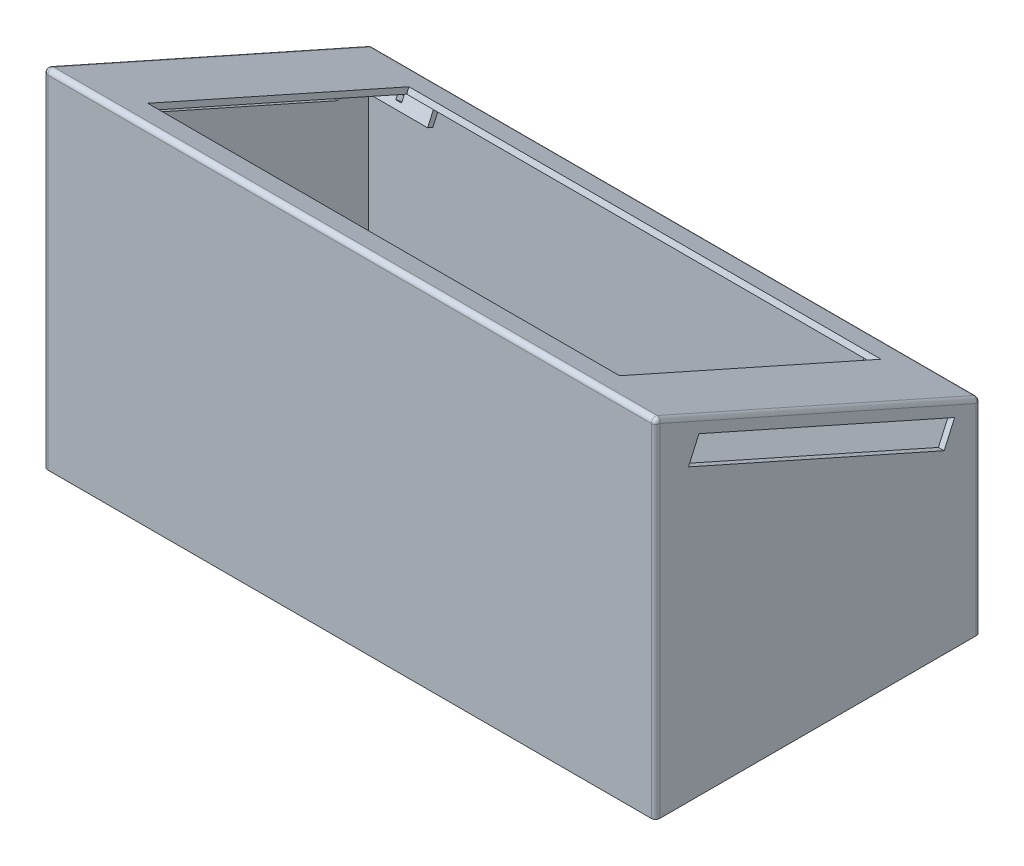
from build123d import *

# Parameters (mm, degrees)
EXTRUDE_1_DEPTH     = 210
SHELL_1_T           = 2
SKETCH_3_W          = 165
SKETCH_3_H          = 100
CUT_EXTRUDE_2_DEPTH = 2
EXTRUDE_2_DEPTH     = 6
CUT_EXTRUDE_3_DEPTH = 2
CUT_EXTRUDE_4_DEPTH = 2
CUT_EXTRUDE_5_DEPTH = 2
FILLET_1_R          = 1.5


with BuildPart() as part:
    # 草图2 → 凸台-拉伸1 (new body)
    with BuildSketch(Plane(origin=(0, 0, 0), x_dir=(0, 0, -1), z_dir=(1, 0, 0))):
        Polygon((0, 0), (0, 118.808397169), (109.625454917, 70), (109.625454917, 0), align=None)
    extrude(amount=EXTRUDE_1_DEPTH)

    # 抽壳1
    shell_1_openings = [part.faces().sort_by_distance(p)[0] for p in [
        (105, 0, -54.812727459),
    ]]
    offset(amount=SHELL_1_T, openings=shell_1_openings, kind=Kind.INTERSECTION)

    # 草图3 → 切除-拉伸2 (cut)
    with BuildSketch(Plane(origin=(0, 99.153366004, -44.14592279), x_dir=(1, 0, 0), z_dir=(0, 0.9135454576426035, -0.4067366430757946))):
        with Locations((105, 11.676271366)):
            Rectangle(SKETCH_3_W, SKETCH_3_H)
    extrude(amount=CUT_EXTRUDE_2_DEPTH, mode=Mode.SUBTRACT)

    # 草图5 → 凸台-拉伸2 (add)
    with BuildSketch(Plane(origin=(0, 99.153366004, -44.14592279), x_dir=(1, 0, 0), z_dir=(0, -0.9135454576426034, 0.4067366430757947))):
        Polygon((9.75, 43.073728634), (29.75, 43.073728634), (29.75, 41.073728634), (9.75, 41.073728634), (9.75, 21.073728634), (7.75, 21.073728634), (7.75, 43.073728634), align=None)
        Polygon((180.25, 43.073728634), (180.25, 41.073728634), (200.25, 41.073728634), (200.25, 21.073728634), (202.25, 21.073728634), (202.25, 43.073728634), (200.25, 43.073728634), align=None)
        Polygon((180.25, -66.426271366), (180.25, -64.426271366), (200.25, -64.426271366), (200.25, -44.426271366), (202.25, -44.426271366), (202.25, -66.426271366), (200.25, -66.426271366), align=None)
        Polygon((29.75, -66.426271366), (29.75, -64.426271366), (9.75, -64.426271366), (9.75, -44.426271366), (7.75, -44.426271366), (7.75, -66.426271366), (9.75, -66.426271366), align=None)
    extrude(amount=EXTRUDE_2_DEPTH)

    # 草图8 → 切除-拉伸3 (cut)
    with BuildSketch(Plane(origin=(0, 97.50898418, -43.413796832), x_dir=(-1, 0, 0), z_dir=(0, -0.9135454576426034, 0.4067366430757947))):
        Polygon((-19.75, -41.073728634), (-21.75, -43.073728634), (-19.75, -43.073728634), (-7.75, -31.073728634), (-7.75, -29.073728634), (-9.75, -31.073728634), align=None)
        Polygon((-19.75, 64.426271366), (-21.75, 66.426271366), (-19.75, 66.426271366), (-7.75, 54.426271366), (-7.75, 52.426271366), (-9.75, 54.426271366), align=None)
        Polygon((-190.25, -41.073728634), (-188.25, -43.073728634), (-190.25, -43.073728634), (-202.25, -31.073728634), (-202.25, -29.073728634), (-200.25, -31.073728634), align=None)
        Polygon((-200.25, 54.426271366), (-202.25, 52.426271366), (-202.25, 54.426271366), (-190.25, 66.426271366), (-188.25, 66.426271366), (-190.25, 64.426271366), align=None)
    extrude(amount=CUT_EXTRUDE_3_DEPTH, mode=Mode.SUBTRACT)

    # 草图10 → 切除-拉伸4 (cut)
    with BuildSketch(Plane.ZY.offset(2)):
        Polygon((-98.902140019, 61.638692052), (-9.521804093, 101.433381509), (-13.182433881, 109.655290628), (-102.562769807, 69.860601171), align=None)
    extrude(amount=-CUT_EXTRUDE_4_DEPTH, mode=Mode.SUBTRACT)

    # 草图11 → 切除-拉伸5 (cut)
    with BuildSketch(Plane(origin=(212, 0, 0), x_dir=(0, 0, -1), z_dir=(1, 0, 0))):
        Polygon((9.521804093, 101.433381509), (13.182433881, 109.655290628), (102.562769807, 69.860601171), (98.902140019, 61.638692052), align=None)
    extrude(amount=-CUT_EXTRUDE_5_DEPTH, mode=Mode.SUBTRACT)

    # 圆角1
    fillet_1_edges = [part.edges().sort_by_distance(p)[0] for p in [
        (212, 96.593471142, -54.812727459),
        (212, 60.944063548, 2),
        (-2, 60.944063548, 2),
        (-2, 96.593471142, -54.812727459),
        (-2, 35.649407593, -111.625454917),
        (105, 121.888127097, 2),
        (105, 71.298815186, -111.625454917),
        (212, 35.649407593, -111.625454917),
    ]]
    fillet(fillet_1_edges, radius=FILLET_1_R)


solid = part.part
